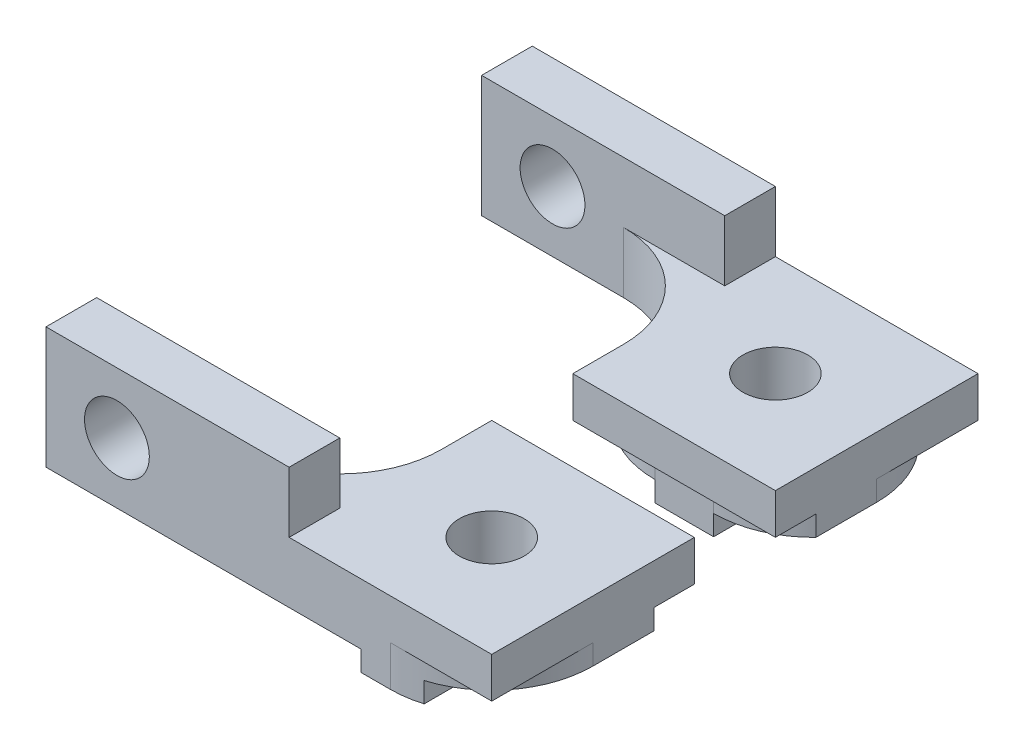
from build123d import *

# Parameters (mm, degrees)
SKETCH1_R          = 1.6
MAIN_DEPTH         = 10
SKETCH2_R          = 1.6
TOPHOLE_DEPTH      = 5
SKETCH3_W          = 12
SKETCH3_H          = 7.5
CUT_EXTRUDE2_DEPTH = 8
FILLET1_R          = 5
CUT_EXTRUDE5_DEPTH = 2


with BuildPart() as part:
    # Sketch1 → Main (new body)
    with BuildSketch(Plane.XY):
        Polygon((0, 0), (-3.55, 0), (-3.55, -1), (-6.45, -1), (-6.45, 0), (-22, 0), (-22, 6), (-10, 6), (-10, 3), (0, 3), align=None)
        with Locations((-18.5, 3)):
            Circle(SKETCH1_R, mode=Mode.SUBTRACT)
    extrude(amount=MAIN_DEPTH)

    # Sketch2 → TopHole (cut, through all)
    with BuildSketch(Plane(origin=(0, 3, 0), x_dir=(1, 0, 0), z_dir=(0, 1, 0))):
        with Locations((-5, -5)):
            Circle(SKETCH2_R)
    extrude(amount=-TOPHOLE_DEPTH, mode=Mode.SUBTRACT)

    # Sketch3 → Cut-Extrude2 (cut, through all)
    with BuildSketch(Plane(origin=(0, 6, 0), x_dir=(1, 0, 0), z_dir=(0, 1, 0))):
        with Locations((-16, -3.75)):
            Rectangle(SKETCH3_W, SKETCH3_H)
    extrude(amount=-CUT_EXTRUDE2_DEPTH, mode=Mode.SUBTRACT)

    # Fillet1
    fillet1_edges = [part.edges().sort_by_distance(p)[0] for p in [
        (-10, 1.5, 7.5),
    ]]
    fillet(fillet1_edges, radius=FILLET1_R)

    # Sketch5 → Cut-Extrude5 (cut)
    with BuildSketch(Plane.XZ.offset(1)):
        with BuildLine():
            Line((-3.55, 0.5), (-6.45, 0.5))
            ThreePointArc((-6.45, 0.5), (-8.376947067, 0.890391941), (-10, 2))
            Line((-10, 2), (-10, 0))
            Line((-10, 0), (0, 0))
            Line((0, 0), (0, 2))
            ThreePointArc((0, 2), (-1.623052933, 0.890391941), (-3.55, 0.5))
        make_face()
        with BuildLine():
            Line((0, 5), (0, 10))
            Line((0, 10), (-5, 10))
            ThreePointArc((-5, 10), (-1.464466094, 8.535533906), (0, 5))
        make_face()
    extrude(amount=-CUT_EXTRUDE5_DEPTH, mode=Mode.SUBTRACT)


with BuildPart() as body_2:
    # Mirror5: mirrored copy
    add(part.part.mirror(Plane.XY.offset(-2)))


solid = Compound([part.part, body_2.part])
